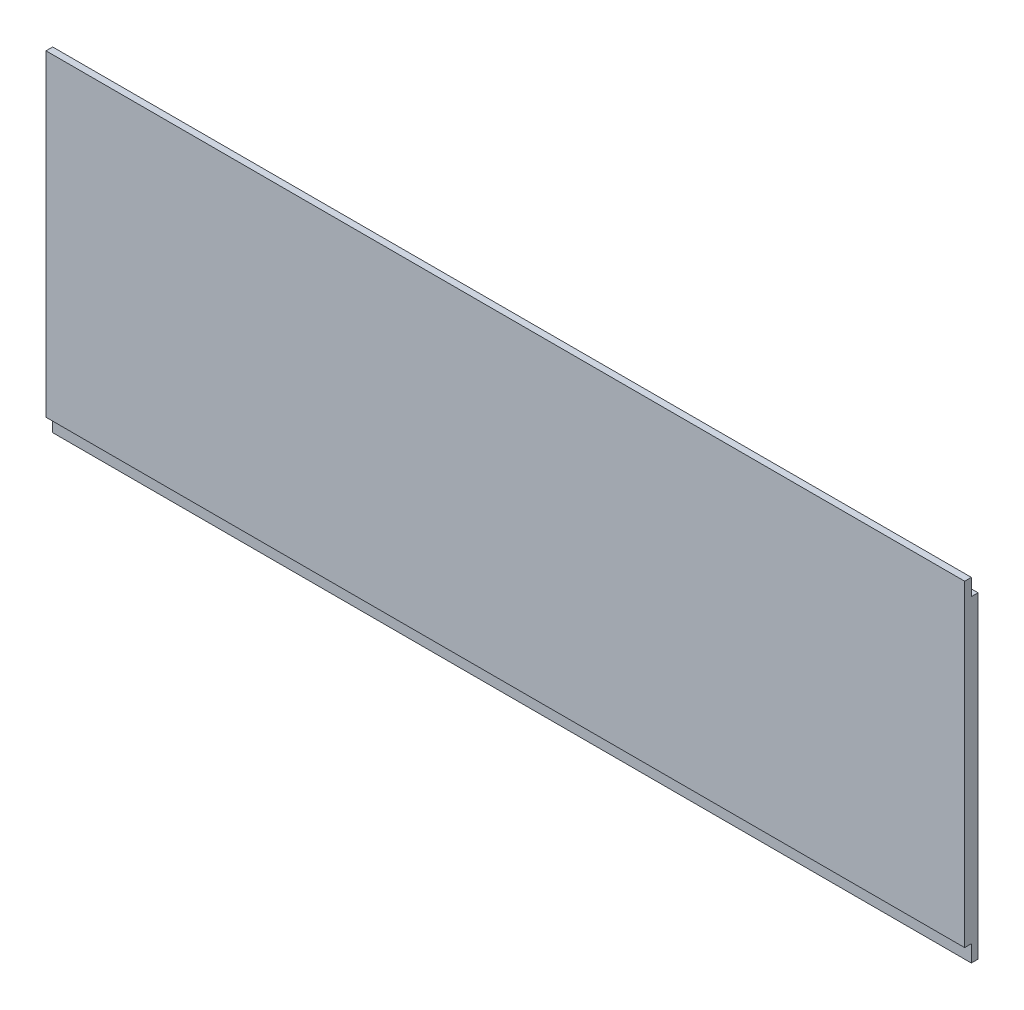
from build123d import *

# Parameters (mm, degrees)
EXTRUDE_1_DEPTH = 550


with BuildPart() as part:
    # Эскиз1 → Бобышка-Вытянуть1 (new body)
    with BuildSketch(Plane(origin=(0, 0, 0), x_dir=(0, 0, -1), z_dir=(1, 0, 0))):
        Polygon((0, 0), (0, 190), (-4, 190), (-4, 200), (-8, 200), (-8, 10), (-4, 10), (-4, 0), align=None)
    extrude(amount=EXTRUDE_1_DEPTH)


solid = part.part
